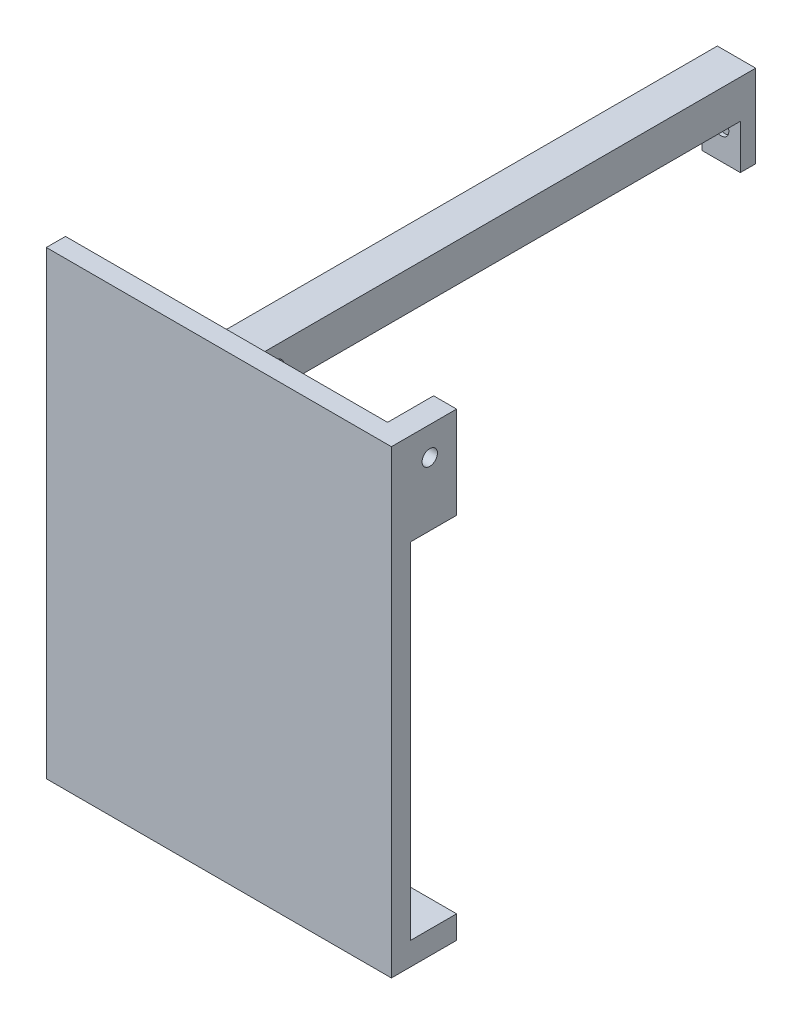
from build123d import *

# Parameters (mm, degrees)
SKETCH1_W               = 50
SKETCH1_H               = 50
BOSS_EXTRUDE1_DEPTH     = 650
SKETCH2_W               = 450
SKETCH2_H               = 600
BOSS_EXTRUDE2_DEPTH     = 25
SKETCH4_W               = 450
SKETCH4_H               = 30
BOSS_EXTRUDE3_DEPTH     = 60
SKETCH5_R               = 10
CUT_EXTRUDE1_DEPTH      = 510
SKETCH7_W               = 50
SKETCH7_H               = 20
BOSS_EXTRUDE4_DEPTH     = 58
SKETCH8_R               = 10
CUT_EXTRUDE3_DEPTH      = 635
CUT_EXTRUDE3_DEPTH_BACK = 20
SKETCH9_W               = 30
SKETCH9_H               = 90
BOSS_EXTRUDE5_DEPTH     = 60
SKETCH10_R              = 10
CUT_EXTRUDE4_DEPTH      = 214


with BuildPart() as part:
    # Sketch1 → Boss-Extrude1 (new body)
    with BuildSketch(Plane.XY):
        with Locations((-10.215053763, 2.150537634)):
            Rectangle(SKETCH1_W, SKETCH1_H)
    extrude(amount=BOSS_EXTRUDE1_DEPTH)

    # Sketch2 → Boss-Extrude2 (add)
    with BuildSketch(Plane.XY.offset(650)):
        with Locations((-10.215053763, -262.849462366)):
            Rectangle(SKETCH2_W, SKETCH2_H)
    extrude(amount=BOSS_EXTRUDE2_DEPTH)

    # Sketch4 → Boss-Extrude3 (add)
    with BuildSketch(Plane(origin=(0, 0, 650), x_dir=(-1, 0, 0), z_dir=(0, 0, -1))):
        with Locations((10.215053763, -547.849462366)):
            Rectangle(SKETCH4_W, SKETCH4_H)
        with Locations((10.215053763, -67.849462366)):
            Rectangle(SKETCH4_W, SKETCH4_H)
    extrude(amount=BOSS_EXTRUDE3_DEPTH)

    # Sketch5 → Cut-Extrude1 (cut)
    with BuildSketch(Plane.XZ.offset(562.849462366)):
        with Locations((-10.215053763, 625)):
            Circle(SKETCH5_R)
    extrude(amount=-CUT_EXTRUDE1_DEPTH, mode=Mode.SUBTRACT)

    # Sketch7 → Boss-Extrude4 (add)
    with BuildSketch(Plane.XZ.offset(22.849462366)):
        with Locations((-10.215053763, 10)):
            Rectangle(SKETCH7_W, SKETCH7_H)
    extrude(amount=BOSS_EXTRUDE4_DEPTH)

    # Sketch8 → Cut-Extrude3 (cut, two sides)
    with BuildSketch(Plane(origin=(0, 0, 650), x_dir=(-1, 0, 0), z_dir=(0, 0, -1))) as cut_extrude3_sk:
        with Locations((10.215053763, -41.849462366)):
            Circle(SKETCH8_R)
    extrude(amount=CUT_EXTRUDE3_DEPTH, mode=Mode.SUBTRACT)
    extrude(cut_extrude3_sk.sketch, amount=-CUT_EXTRUDE3_DEPTH_BACK, mode=Mode.SUBTRACT)

    # Sketch9 → Boss-Extrude5 (add)
    with BuildSketch(Plane(origin=(0, 0, 650), x_dir=(-1, 0, 0), z_dir=(0, 0, -1))):
        with Locations((-199.784946237, -7.849462366)):
            Rectangle(SKETCH9_W, SKETCH9_H)
    extrude(amount=BOSS_EXTRUDE5_DEPTH)

    # Sketch10 → Cut-Extrude4 (cut)
    with BuildSketch(Plane(origin=(214.784946237, 0, 0), x_dir=(0, 0, -1), z_dir=(1, 0, 0))):
        with Locations((-625, 0)):
            Circle(SKETCH10_R)
    extrude(amount=-CUT_EXTRUDE4_DEPTH, mode=Mode.SUBTRACT)


solid = part.part
